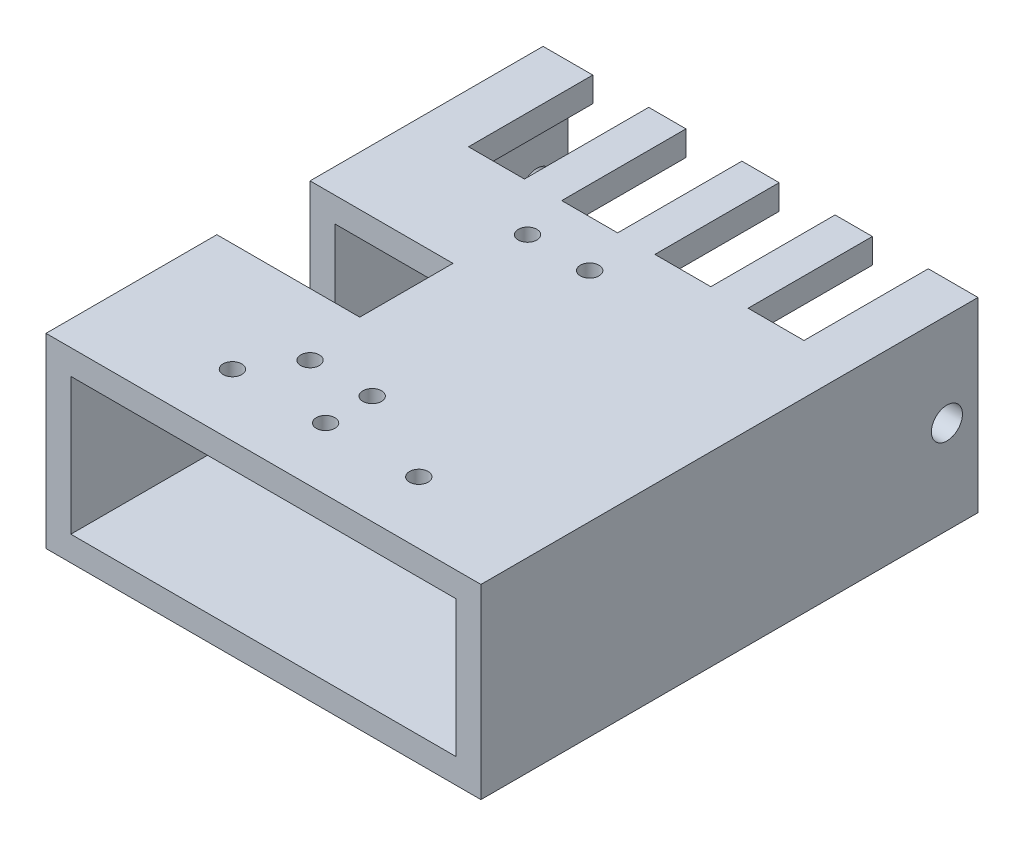
from build123d import *

# Parameters (mm, degrees)
SKETCH1_W               = 88.9
SKETCH1_H               = 101.6
BOSS_EXTRUDE1_DEPTH     = 38.1
SHELL1_T                = -5.08
CUT_EXTRUDE3_START      = -19.05
SKETCH4_W               = 29.21
SKETCH4_H               = 19.05
CUT_EXTRUDE3_DEPTH      = 20.05
SKETCH5_W               = 11.43
SKETCH5_H               = 25.4
CUT_EXTRUDE4_DEPTH      = 39.1
SKETCH6_R               = 3.175
CUT_EXTRUDE5_DEPTH      = 4.2672
CUT_EXTRUDE5_DEPTH_BACK = 89.9
CUT_EXTRUDE6_REACH      = 40.1
SKETCH7_R               = 1.905
SKETCH9_W               = 10.16
SKETCH9_H               = 6.35
BOSS_EXTRUDE2_DEPTH     = 6.35
SKETCH10_R              = 2.38125
CUT_EXTRUDE7_DEPTH      = 30.48


with BuildPart() as part:
    # Sketch1 → Boss-Extrude1 (new body)
    with BuildSketch(Plane(origin=(0, 0, 0), x_dir=(1, 0, 0), z_dir=(0, 1, 0))):
        with Locations((44.45, 50.8)):
            Rectangle(SKETCH1_W, SKETCH1_H)
    extrude(amount=BOSS_EXTRUDE1_DEPTH)

    # Shell1
    shell1_openings = [part.faces().sort_by_distance(p)[0] for p in [
        (44.45, 19.05, 0),
        (44.45, 19.05, -101.6),
    ]]
    offset(amount=SHELL1_T, openings=shell1_openings, kind=Kind.INTERSECTION)

    # Sketch4 → Cut-Extrude3 (cut, through all)
    with BuildSketch(Plane.XZ.offset(CUT_EXTRUDE3_START)):
        with Locations((14.605, -44.45)):
            Rectangle(SKETCH4_W, SKETCH4_H)
    extrude(amount=-CUT_EXTRUDE3_DEPTH, mode=Mode.SUBTRACT)

    # Sketch5 → Cut-Extrude4 (cut, through all)
    with BuildSketch(Plane(origin=(0, 38.1, 0), x_dir=(1, 0, 0), z_dir=(0, 1, 0))):
        with Locations((15.875, 88.9)):
            Rectangle(SKETCH5_W, SKETCH5_H)
        with Locations((34.925, 88.9)):
            Rectangle(SKETCH5_W, SKETCH5_H)
        with Locations((53.975, 88.9)):
            Rectangle(SKETCH5_W, SKETCH5_H)
        with Locations((73.025, 88.9)):
            Rectangle(SKETCH5_W, SKETCH5_H)
    extrude(amount=-CUT_EXTRUDE4_DEPTH, mode=Mode.SUBTRACT)

    # Sketch6 → Cut-Extrude5 (cut, two sides)
    with BuildSketch(Plane.ZY) as cut_extrude5_sk:
        with Locations((-95.25, 19.05)):
            Circle(SKETCH6_R)
    extrude(amount=CUT_EXTRUDE5_DEPTH, mode=Mode.SUBTRACT)
    extrude(cut_extrude5_sk.sketch, amount=-CUT_EXTRUDE5_DEPTH_BACK, mode=Mode.SUBTRACT)

    # Sketch7 → Cut-Extrude6 (cut, up to next)
    with BuildSketch(Plane(origin=(0, 38.1, 0), x_dir=(1, 0, 0), z_dir=(0, 1, 0)), mode=Mode.PRIVATE) as cut_extrude6_sk1:
        with Locations((44.45, 12.7)):
            Circle(SKETCH7_R)
    cut_extrude6_tool1 = extrude(cut_extrude6_sk1.sketch, amount=-CUT_EXTRUDE6_REACH, mode=Mode.PRIVATE) & part.part
    add(cut_extrude6_tool1.solids().sort_by_distance((44.45, 38.1, -12.7))[0], mode=Mode.SUBTRACT)
    # Sketch7 → Cut-Extrude6 (cut, up to next)
    with BuildSketch(Plane(origin=(0, 38.1, 0), x_dir=(1, 0, 0), z_dir=(0, 1, 0)), mode=Mode.PRIVATE) as cut_extrude6_sk2:
        with Locations((25.4, 12.7)):
            Circle(SKETCH7_R)
    cut_extrude6_tool2 = extrude(cut_extrude6_sk2.sketch, amount=-CUT_EXTRUDE6_REACH, mode=Mode.PRIVATE) & part.part
    add(cut_extrude6_tool2.solids().sort_by_distance((25.4, 38.1, -12.7))[0], mode=Mode.SUBTRACT)
    # Sketch7 → Cut-Extrude6 (cut, up to next)
    with BuildSketch(Plane(origin=(0, 38.1, 0), x_dir=(1, 0, 0), z_dir=(0, 1, 0)), mode=Mode.PRIVATE) as cut_extrude6_sk3:
        with Locations((63.5, 12.7)):
            Circle(SKETCH7_R)
    cut_extrude6_tool3 = extrude(cut_extrude6_sk3.sketch, amount=-CUT_EXTRUDE6_REACH, mode=Mode.PRIVATE) & part.part
    add(cut_extrude6_tool3.solids().sort_by_distance((63.5, 38.1, -12.7))[0], mode=Mode.SUBTRACT)
    # Sketch7 → Cut-Extrude6 (cut, up to next)
    with BuildSketch(Plane(origin=(0, 38.1, 0), x_dir=(1, 0, 0), z_dir=(0, 1, 0)), mode=Mode.PRIVATE) as cut_extrude6_sk4:
        with Locations((31.75, 66.675)):
            Circle(SKETCH7_R)
    cut_extrude6_tool4 = extrude(cut_extrude6_sk4.sketch, amount=-CUT_EXTRUDE6_REACH, mode=Mode.PRIVATE) & part.part
    add(cut_extrude6_tool4.solids().sort_by_distance((31.75, 38.1, -66.675))[0], mode=Mode.SUBTRACT)
    # Sketch7 → Cut-Extrude6 (cut, up to next)
    with BuildSketch(Plane(origin=(0, 38.1, 0), x_dir=(1, 0, 0), z_dir=(0, 1, 0)), mode=Mode.PRIVATE) as cut_extrude6_sk5:
        with Locations((44.45, 66.675)):
            Circle(SKETCH7_R)
    cut_extrude6_tool5 = extrude(cut_extrude6_sk5.sketch, amount=-CUT_EXTRUDE6_REACH, mode=Mode.PRIVATE) & part.part
    add(cut_extrude6_tool5.solids().sort_by_distance((44.45, 38.1, -66.675))[0], mode=Mode.SUBTRACT)
    # Sketch7 → Cut-Extrude6 (cut, up to next)
    with BuildSketch(Plane(origin=(0, 38.1, 0), x_dir=(1, 0, 0), z_dir=(0, 1, 0)), mode=Mode.PRIVATE) as cut_extrude6_sk6:
        with Locations((44.45, 22.225)):
            Circle(SKETCH7_R)
    cut_extrude6_tool6 = extrude(cut_extrude6_sk6.sketch, amount=-CUT_EXTRUDE6_REACH, mode=Mode.PRIVATE) & part.part
    add(cut_extrude6_tool6.solids().sort_by_distance((44.45, 38.1, -22.225))[0], mode=Mode.SUBTRACT)
    # Sketch7 → Cut-Extrude6 (cut, up to next)
    with BuildSketch(Plane(origin=(0, 38.1, 0), x_dir=(1, 0, 0), z_dir=(0, 1, 0)), mode=Mode.PRIVATE) as cut_extrude6_sk7:
        with Locations((31.75, 22.225)):
            Circle(SKETCH7_R)
    cut_extrude6_tool7 = extrude(cut_extrude6_sk7.sketch, amount=-CUT_EXTRUDE6_REACH, mode=Mode.PRIVATE) & part.part
    add(cut_extrude6_tool7.solids().sort_by_distance((31.75, 38.1, -22.225))[0], mode=Mode.SUBTRACT)

    # Sketch9 → Boss-Extrude2 (add)
    with BuildSketch(Plane.ZY):
        with Locations((-34.29, 3.175)):
            Rectangle(SKETCH9_W, SKETCH9_H)
        with Locations((-54.61, 3.175)):
            Rectangle(SKETCH9_W, SKETCH9_H)
    extrude(amount=BOSS_EXTRUDE2_DEPTH)

    # Sketch10 → Cut-Extrude7 (cut)
    with BuildSketch(Plane.XY.offset(-29.21)):
        with Locations((-3.175, 3.175)):
            Circle(SKETCH10_R)
        with BuildLine():
            Line((-3.175, 7.665128061), (-3.175, 6.35))
            ThreePointArc((-3.175, 6.35), (-6.35, 3.175), (-3.175, 0))
            Line((-3.175, 0), (-3.175, -1.315128061))
            ThreePointArc((-3.175, -1.315128061), (-7.665128061, 3.175), (-3.175, 7.665128061))
        make_face()
    extrude(amount=-CUT_EXTRUDE7_DEPTH, mode=Mode.SUBTRACT)


solid = part.part
